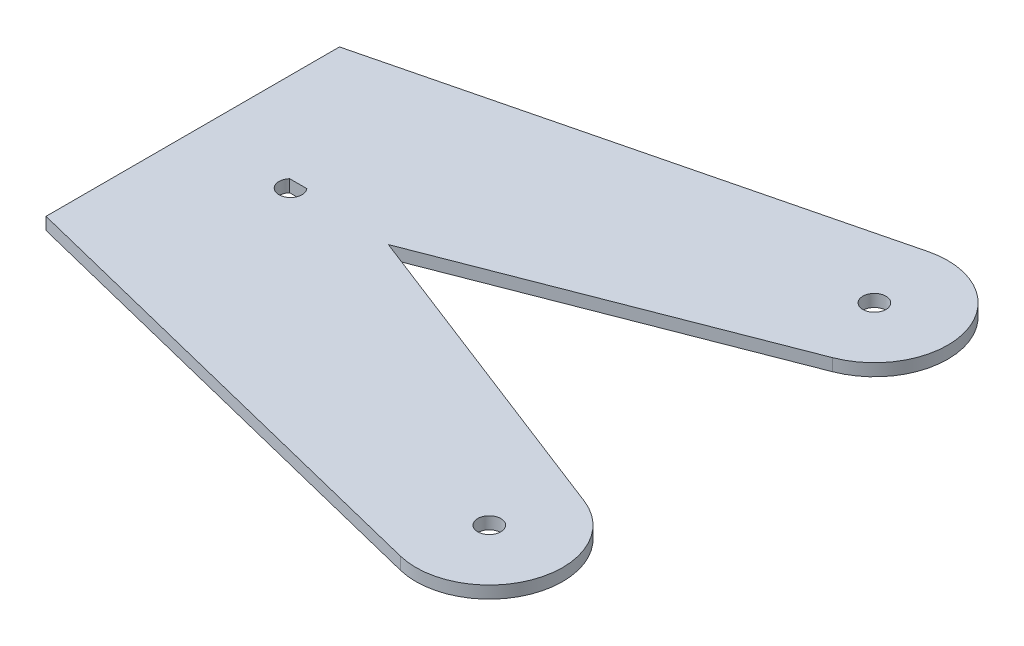
from build123d import *

# Parameters (mm, degrees)
SKETCH1_R           = 3
BOSS_EXTRUDE1_DEPTH = 1.5875


with BuildPart() as part:
    # Sketch1 → Boss-Extrude1 (new body, symmetric)
    with BuildSketch(Plane(origin=(0, 0, 0), x_dir=(1, 0, 0), z_dir=(0, 1, 0))):
        with BuildLine():
            Line((-25.4, 38.1), (97.010086235, 68.488785564))
            ThreePointArc((97.010086235, 68.488785564), (119.760857484, 55.752021858), (108.491020074, 32.240035407))
            Line((108.491020074, 32.240035407), (25.4, 0))
            Line((25.4, 0), (108.491020074, -32.240035407))
            ThreePointArc((108.491020074, -32.240035407), (119.760857484, -55.752021858), (97.010086235, -68.488785564))
            Line((97.010086235, -68.488785564), (-25.4, -38.1))
            Line((-25.4, -38.1), (-25.4, 38.1))
        make_face()
        with Locations((101.6, 50)):
            Circle(SKETCH1_R, mode=Mode.SUBTRACT)
        with Locations((101.6, -50)):
            Circle(SKETCH1_R, mode=Mode.SUBTRACT)
        with BuildLine():
            Line((-2.236067977, 2), (2.236067977, 2))
            ThreePointArc((2.236067977, 2), (0, -3), (-2.236067977, 2))
        make_face(mode=Mode.SUBTRACT)
    extrude(amount=BOSS_EXTRUDE1_DEPTH, both=True)


solid = part.part
